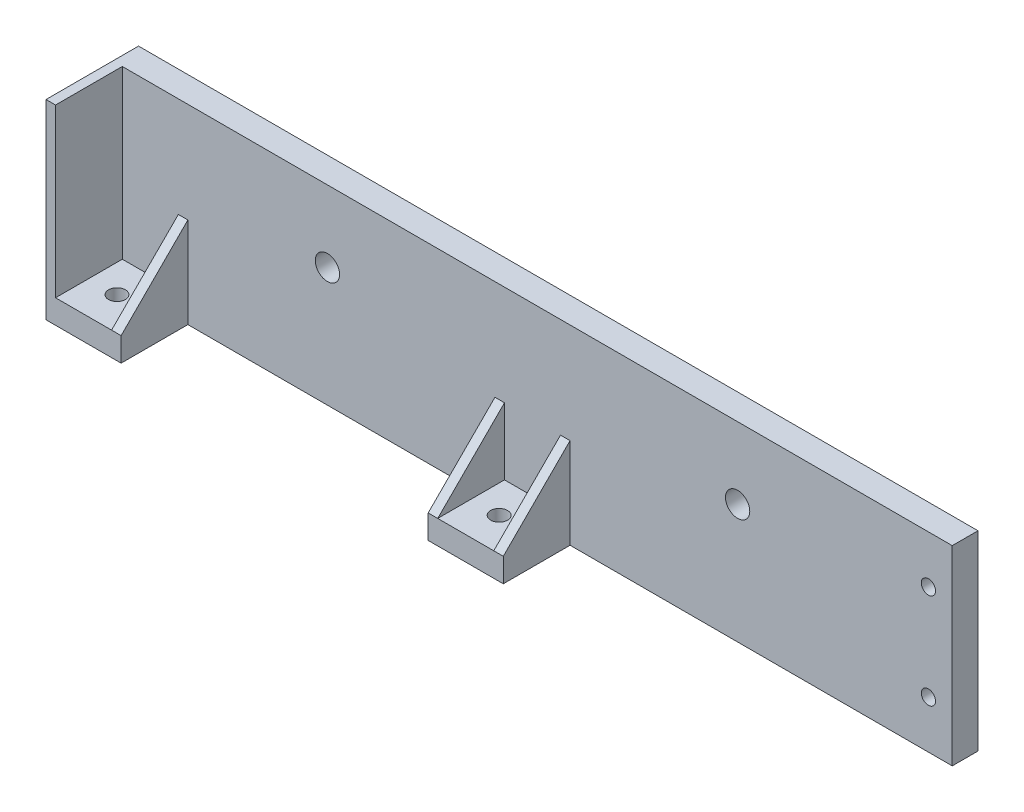
from build123d import *

# Parameters (mm, degrees)
SKETCH1_W                                      = 223.52
SKETCH1_H                                      = 50.8
SKETCH1_R                                      = 3.2385
BOSS_EXTRUDE1_DEPTH                            = 6.858
SKETCH2_W                                      = 20
SKETCH2_H                                      = 6.35
BOSS_EXTRUDE2_DEPTH                            = 17.78
SKETCH3_R                                      = 2.25
CUT_EXTRUDE1_DEPTH                             = 17.78
SKETCH4_W                                      = 2.54
SKETCH4_H                                      = 17.78
BOSS_EXTRUDE3_DEPTH                            = 17.78
CUT_EXTRUDE2_DEPTH                             = 20
LPATTERN1_COUNT                                = 2
LPATTERN1_PITCH                                = 101.76
BOSS_EXTRUDE4_DEPTH                            = 2.54
CSK_FOR_6_FLAT_HEAD_MACHINE_SCREW1_D           = 3.7973
CSK_FOR_6_FLAT_HEAD_MACHINE_SCREW1_CSINK_D     = 7.9697834
CSK_FOR_6_FLAT_HEAD_MACHINE_SCREW1_CSINK_ANGLE = 82


with BuildPart() as part:
    # Sketch1 → Boss-Extrude1 (new body)
    with BuildSketch(Plane.XY):
        Rectangle(SKETCH1_W, SKETCH1_H)
        with Locations((-54.61, 6.35)):
            Circle(SKETCH1_R, mode=Mode.SUBTRACT)
        with Locations((54.61, 6.35)):
            Circle(SKETCH1_R, mode=Mode.SUBTRACT)
    extrude(amount=BOSS_EXTRUDE1_DEPTH)

    # Sketch2 → Boss-Extrude2 (add)
    with BuildSketch(Plane.XY.offset(6.858)):
        with Locations((-101.76, -22.225)):
            Rectangle(SKETCH2_W, SKETCH2_H)
    boss_extrude2 = extrude(amount=BOSS_EXTRUDE2_DEPTH)

    # Sketch3 → Cut-Extrude1 (cut)
    with BuildSketch(Plane(origin=(0, -19.05, 0), x_dir=(1, 0, 0), z_dir=(0, 1, 0))):
        with Locations((-101.76, -15.748)):
            Circle(SKETCH3_R)
    cut_extrude1 = extrude(amount=-CUT_EXTRUDE1_DEPTH, mode=Mode.SUBTRACT)

    # Sketch4 → Boss-Extrude3 (add)
    with BuildSketch(Plane(origin=(0, -19.05, 0), x_dir=(1, 0, 0), z_dir=(0, 1, 0))):
        with Locations((-110.49, -15.748)):
            Rectangle(SKETCH4_W, SKETCH4_H)
        with Locations((-93.03, -15.748)):
            Rectangle(SKETCH4_W, SKETCH4_H)
    boss_extrude3 = extrude(amount=BOSS_EXTRUDE3_DEPTH)

    # Sketch6 → Cut-Extrude2 (cut)
    with BuildSketch(Plane.ZY.offset(111.76)):
        Polygon((24.638, -1.27), (6.858, -1.27), (24.638, -19.05), align=None)
    cut_extrude2 = extrude(amount=-CUT_EXTRUDE2_DEPTH, mode=Mode.SUBTRACT)

    # LPattern1: Boss-Extrude2, Cut-Extrude1, Boss-Extrude3, Cut-Extrude2 ×2
    with Locations(*[(i * LPATTERN1_PITCH, 0, 0) for i in range(1, LPATTERN1_COUNT)]):
        add(boss_extrude2)
        add(cut_extrude1, mode=Mode.SUBTRACT)
        add(boss_extrude3)
        add(cut_extrude2, mode=Mode.SUBTRACT)

    # Sketch7 → Boss-Extrude4 (add)
    with BuildSketch(Plane.ZY.offset(111.76)):
        Polygon((24.638, -19.05), (24.638, 25.4), (6.858, 25.4), (6.858, -1.27), align=None)
    extrude(amount=-BOSS_EXTRUDE4_DEPTH)

    # CSK for #6 Flat Head Machine Screw1 (through all)
    with Locations(Plane(origin=(0, 0, 0), x_dir=(-1, 0, 0), z_dir=(0, 0, -1))):
        with Locations((-105.41, 12.7), (-105.41, -12.7)):
            CounterSinkHole(CSK_FOR_6_FLAT_HEAD_MACHINE_SCREW1_D / 2, CSK_FOR_6_FLAT_HEAD_MACHINE_SCREW1_CSINK_D / 2, counter_sink_angle=CSK_FOR_6_FLAT_HEAD_MACHINE_SCREW1_CSINK_ANGLE)


solid = part.part
